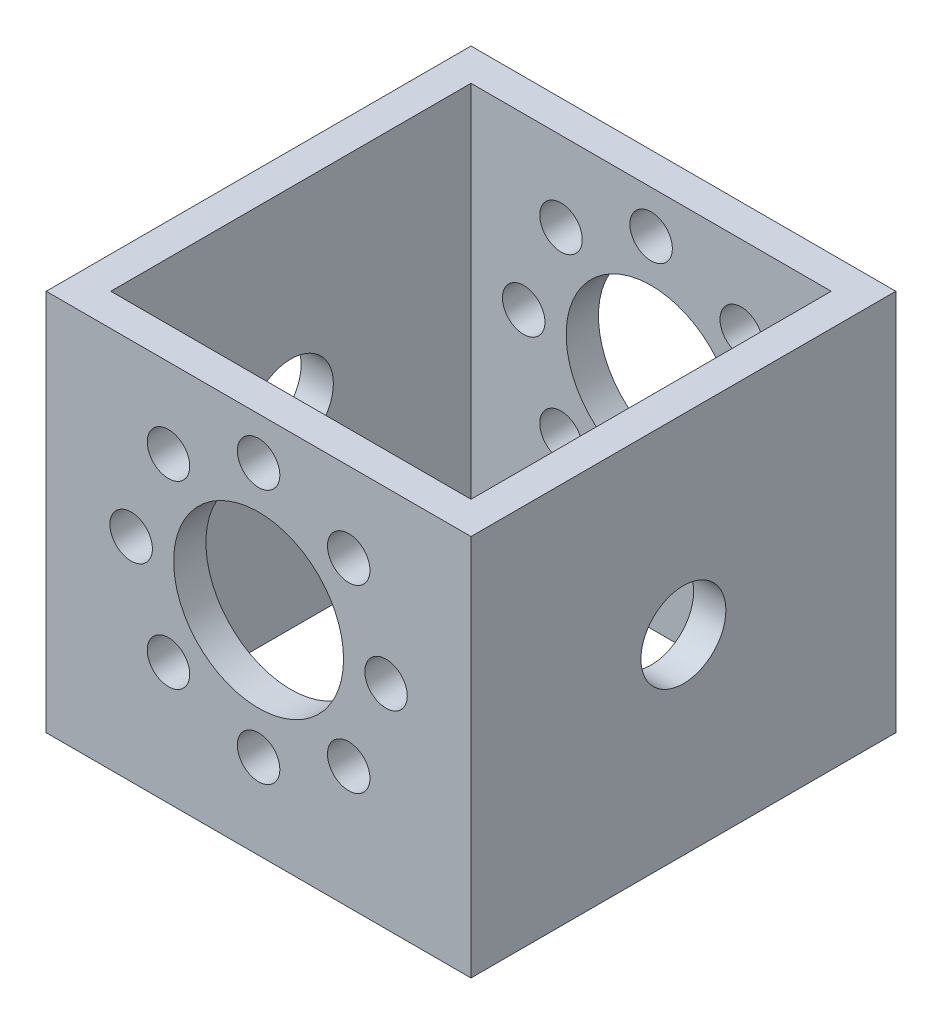
from build123d import *

# Parameters (mm, degrees)
SKETCH1_W           = 63.5
SKETCH1_H           = 57.15
SKETCH1_R           = 12.7
SKETCH1_R_2         = 3.175
BOSS_EXTRUDE2_DEPTH = 4.826
SKETCH2_W           = 53.848
SKETCH2_H           = 57.15
SKETCH2_R           = 6.35
BOSS_EXTRUDE3_DEPTH = 4.826


with BuildPart() as part:
    # Sketch1 → Boss-Extrude2 (new body)
    with BuildSketch(Plane.XY):
        with Locations((0, -3.175)):
            Rectangle(SKETCH1_W, SKETCH1_H)
        Circle(SKETCH1_R, mode=Mode.SUBTRACT)
        with Locations((0, 19.05)):
            Circle(SKETCH1_R_2, mode=Mode.SUBTRACT)
        with Locations((13.470384182, 13.470384182)):
            Circle(SKETCH1_R_2, mode=Mode.SUBTRACT)
        with Locations((19.05, 0)):
            Circle(SKETCH1_R_2, mode=Mode.SUBTRACT)
        with Locations((13.470384182, -13.470384182)):
            Circle(SKETCH1_R_2, mode=Mode.SUBTRACT)
        with Locations((0, -19.05)):
            Circle(SKETCH1_R_2, mode=Mode.SUBTRACT)
        with Locations((-13.470384182, -13.470384182)):
            Circle(SKETCH1_R_2, mode=Mode.SUBTRACT)
        with Locations((-19.05, 0)):
            Circle(SKETCH1_R_2, mode=Mode.SUBTRACT)
        with Locations((-13.470384182, 13.470384182)):
            Circle(SKETCH1_R_2, mode=Mode.SUBTRACT)
    boss_extrude2 = extrude(amount=BOSS_EXTRUDE2_DEPTH)

    # Sketch2 → Boss-Extrude3 (add)
    with BuildSketch(Plane(origin=(31.75, 0, 0), x_dir=(0, 0, -1), z_dir=(1, 0, 0))):
        with Locations((-31.75, -3.175)):
            Rectangle(SKETCH2_W, SKETCH2_H)
        with Locations((-31.75, -3.175)):
            Circle(SKETCH2_R, mode=Mode.SUBTRACT)
    boss_extrude3 = extrude(amount=-BOSS_EXTRUDE3_DEPTH)

    # Mirror1: Boss-Extrude2 across plane
    add(boss_extrude2.mirror(Plane.XY.offset(31.75)))

    # Mirror3: Boss-Extrude3 across plane
    add(boss_extrude3.mirror(Plane.ZY))


solid = part.part
